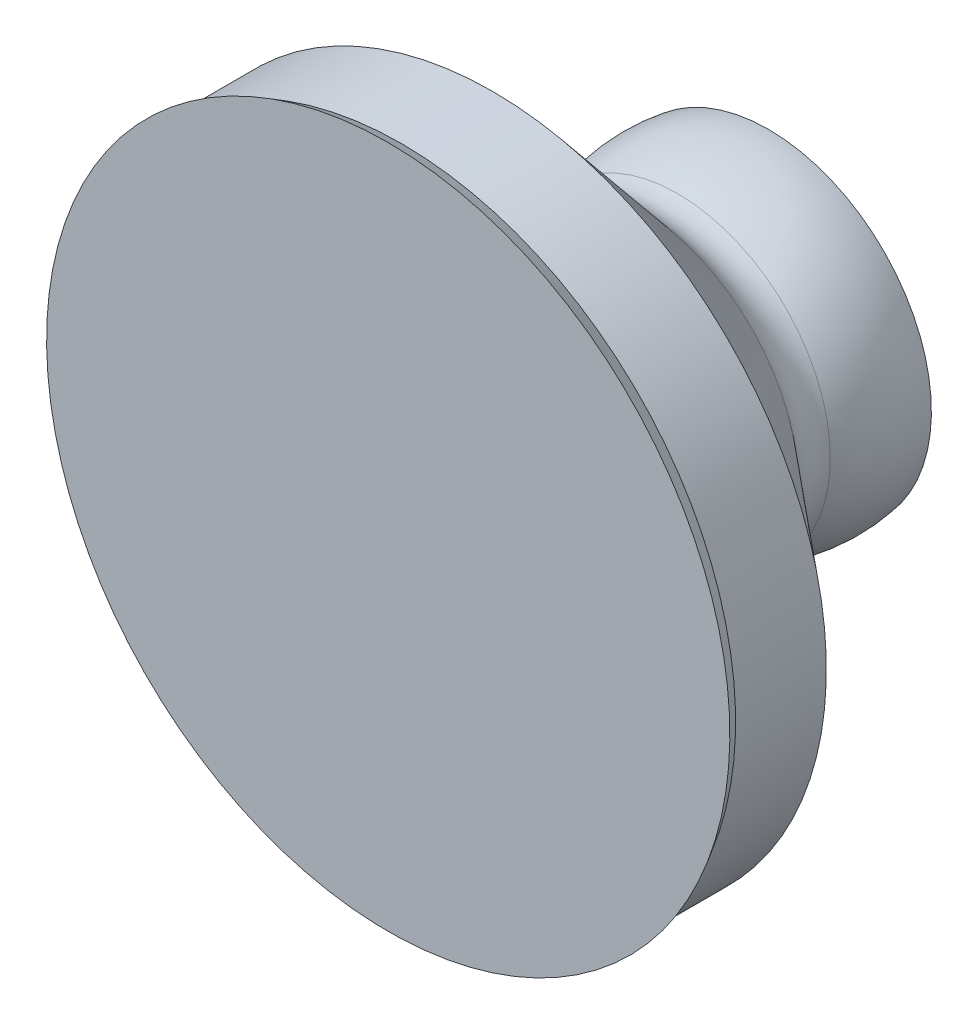
from build123d import *


with BuildPart() as part:
    # Sketch1 → Revolve1 (revolve)
    with BuildSketch(Plane(origin=(0, 0, 0), x_dir=(0, 0, -1), z_dir=(1, 0, 0))):
        with BuildLine():
            Line((0, 0), (-50.959835356, 0))
            Line((-50.959835356, 0), (-83.8211217, 0))
            Line((-83.8211217, 0), (-83.8211217, 75.282050808))
            Line((-83.8211217, 75.282050808), (-80.8211217, 73.55))
            Line((-80.8211217, 73.55), (-60.8211217, 73.55))
            Line((-60.8211217, 73.55), (-29.224979598, 35.895184138))
            ThreePointArc((-29.224979598, 35.895184138), (-25.002056634, 33.267714962), (-20.042663952, 33.643343571))
            ThreePointArc((-20.042663952, 33.643343571), (-10.179122164, 36.1760026), (0, 35.877187771))
            Line((0, 35.877187771), (0, 34.862194457))
            Line((0, 34.862194457), (0, 0))
        make_face()
    revolve(axis=Axis((0, 0, 0), (0, 0, 1)))


solid = part.part
